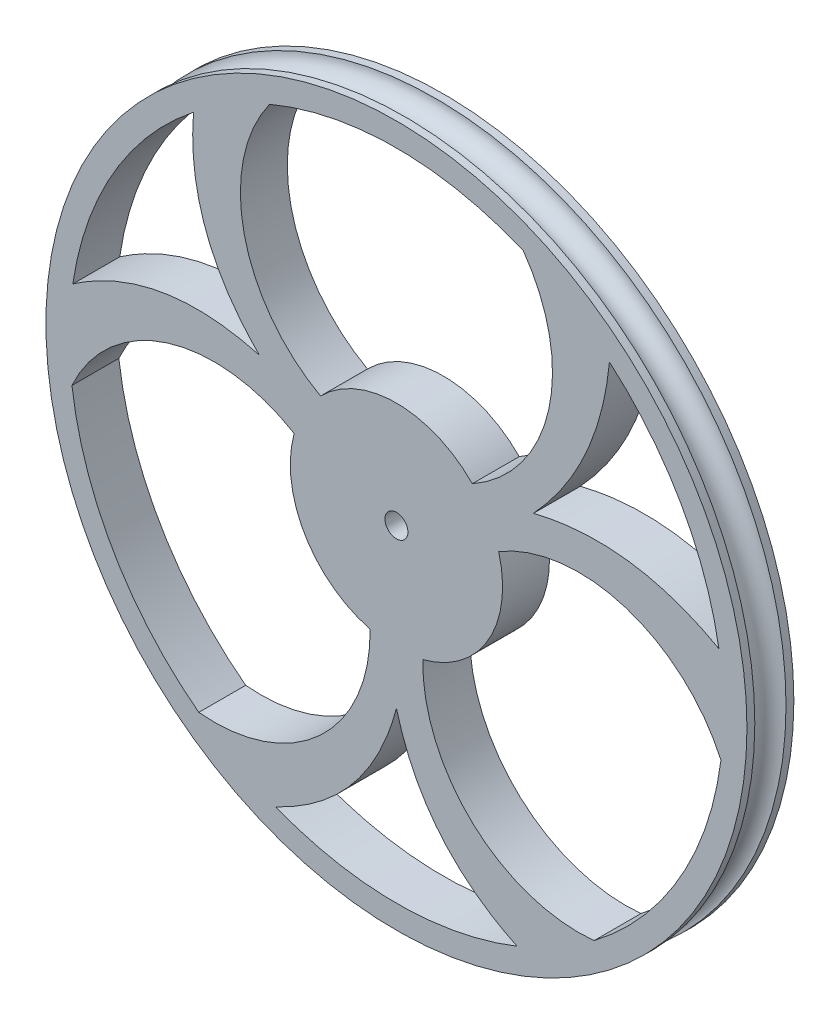
from build123d import *

# Parameters (mm, degrees)
BOSS_EXTRUDE1_REACH                             = 4.654
BOSS_EXTRUDE1_DIRECTION_2_REACH                 = 4.654
CSK_FOR_M2_RAISED_CROSS_HEAD_SCREW1_D           = 2.6
CSK_FOR_M2_RAISED_CROSS_HEAD_SCREW1_CSINK_D     = 4.6
CSK_FOR_M2_RAISED_CROSS_HEAD_SCREW1_CSINK_ANGLE = 92


with BuildPart() as part:
    # Sketch4 → Revolve3 (revolve)
    with BuildSketch(Plane(origin=(0, 0, 0), x_dir=(0, 0, -1), z_dir=(1, 0, 0))):
        with BuildLine():
            Line((-2.6543, -39.6621), (-1.7653, -39.6621))
            ThreePointArc((-1.7653, -39.6621), (0, -37.8968), (1.7653, -39.6621))
            Line((1.7653, -39.6621), (2.6543, -39.6621))
            Line((2.6543, -39.6621), (2.6543, -37.0078))
            Line((2.6543, -37.0078), (-2.6543, -37.0078))
            Line((-2.6543, -37.0078), (-2.6543, -39.6621))
        make_face()
    revolve(axis=Axis((0, 0, 1.7653), (0, 0, -1)))

    # Boss-Extrude1: up to this face of the body (flat: up to its plane)
    boss_extrude1_end = Plane(part.part.faces().sort_by_distance((0, 38.540286405, -2.6543))[0])
    # Sketch5 → Boss-Extrude1 (add, up to the picked face)
    with BuildSketch(Plane.XY, mode=Mode.PRIVATE) as boss_extrude1_sk1:
        with BuildLine():
            ThreePointArc((2.978912783, -11.636990203), (10.402888866, -6.006110687), (11.56738553, 3.238680956))
            ThreePointArc((11.56738553, 3.238680956), (26.749196364, 4.65193852), (37.371776023, -6.286319044))
            ThreePointArc((37.371776023, -6.286319044), (37.895229039, -0.345059896), (37.48005165, 5.604746073))
            add(Edge.make_bspline(
                [(15.506400774, 8.952624661), (27.141070528, 11.852195949), (37.48005165, 5.604746073)],
                knots=[0, 0, 0, 1, 1, 1], degree=2))
            add(Edge.make_bspline(
                [(15.506400774, 8.952624661), (23.43091271, 17.496942665), (24.189816075, 29.172251345)],
                knots=[0, 0, 0, 1, 1, 1], degree=2))
            ThreePointArc((24.189816075, 29.172251345), (18.982008892, 32.800164461), (13.241776023, 35.508066943))
            ThreePointArc((13.241776023, 35.508066943), (17.403295117, 20.839514322), (8.588472748, 8.398309247))
            ThreePointArc((8.588472748, 8.398309247), (0, 12.012221374), (-8.588472748, 8.398309247))
            ThreePointArc((-8.588472748, 8.398309247), (-17.403295117, 20.839514322), (-13.241776023, 35.508066943))
            ThreePointArc((-13.241776023, 35.508066943), (-18.231527824, 33.22316727), (-22.83893963, 30.241532482))
            add(Edge.make_bspline(
                [(-15.506400774, 8.952624661), (-24.330033969, 17.722070983), (-22.83893963, 30.241532482)],
                knots=[0, 0, 0, 1, 1, 1], degree=2))
            add(Edge.make_bspline(
                [(-15.506400774, 8.952624661), (-27.512780663, 12.209392), (-37.609405193, 4.658335674)],
                knots=[0, 0, 0, 1, 1, 1], degree=2))
            ThreePointArc((-37.609405193, 4.658335674), (-37.887870762, -0.822617389), (-37.371776023, -6.286319044))
            ThreePointArc((-37.371776023, -6.286319044), (-26.749196364, 4.65193852), (-11.56738553, 3.238680956))
            ThreePointArc((-11.56738553, 3.238680956), (-10.402888866, -6.006110687), (-2.978912783, -11.636990203))
            ThreePointArc((-2.978912783, -11.636990203), (-9.345901247, -25.491452842), (-24.13, -29.221747898))
            ThreePointArc((-24.13, -29.221747898), (-19.656342938, -32.400549881), (-14.770465564, -34.899868156))
            add(Edge.make_bspline(
                [(0, -17.905249322), (-3.182746695, -29.931462983), (-14.770465564, -34.899868156)],
                knots=[0, 0, 0, 1, 1, 1], degree=2))
            add(Edge.make_bspline(
                [(0, -17.905249322), (3.182746695, -29.931462983), (14.770465564, -34.899868156)],
                knots=[0, 0, 0, 1, 1, 1], degree=2))
            ThreePointArc((14.770465564, -34.899868156), (19.656342938, -32.400549881), (24.13, -29.221747898))
            ThreePointArc((24.13, -29.221747898), (9.345901247, -25.491452842), (2.978912783, -11.636990203))
        make_face()
    boss_extrude1_tool1 = split(extrude(boss_extrude1_sk1.sketch, amount=-BOSS_EXTRUDE1_REACH, mode=Mode.PRIVATE), bisect_by=boss_extrude1_end, keep=Keep.BOTH, mode=Mode.PRIVATE)
    add(boss_extrude1_tool1.solids().sort_by_distance((0.196494, 0.141193, 0))[0])

    # Boss-Extrude1 direction 2: up to this face of the body (flat: up to its plane)
    boss_extrude1_direction_2_end = Plane(part.part.faces().sort_by_distance((0, 38.129613595, 2.6543))[0])
    # Sketch5 → Boss-Extrude1 direction 2 (add, up to the picked face)
    with BuildSketch(Plane.XY, mode=Mode.PRIVATE) as boss_extrude1_direction_2_sk1:
        with BuildLine():
            ThreePointArc((2.978912783, -11.636990203), (10.402888866, -6.006110687), (11.56738553, 3.238680956))
            ThreePointArc((11.56738553, 3.238680956), (26.749196364, 4.65193852), (37.371776023, -6.286319044))
            ThreePointArc((37.371776023, -6.286319044), (37.895229039, -0.345059896), (37.48005165, 5.604746073))
            add(Edge.make_bspline(
                [(15.506400774, 8.952624661), (27.141070528, 11.852195949), (37.48005165, 5.604746073)],
                knots=[0, 0, 0, 1, 1, 1], degree=2))
            add(Edge.make_bspline(
                [(15.506400774, 8.952624661), (23.43091271, 17.496942665), (24.189816075, 29.172251345)],
                knots=[0, 0, 0, 1, 1, 1], degree=2))
            ThreePointArc((24.189816075, 29.172251345), (18.982008892, 32.800164461), (13.241776023, 35.508066943))
            ThreePointArc((13.241776023, 35.508066943), (17.403295117, 20.839514322), (8.588472748, 8.398309247))
            ThreePointArc((8.588472748, 8.398309247), (0, 12.012221374), (-8.588472748, 8.398309247))
            ThreePointArc((-8.588472748, 8.398309247), (-17.403295117, 20.839514322), (-13.241776023, 35.508066943))
            ThreePointArc((-13.241776023, 35.508066943), (-18.231527824, 33.22316727), (-22.83893963, 30.241532482))
            add(Edge.make_bspline(
                [(-15.506400774, 8.952624661), (-24.330033969, 17.722070983), (-22.83893963, 30.241532482)],
                knots=[0, 0, 0, 1, 1, 1], degree=2))
            add(Edge.make_bspline(
                [(-15.506400774, 8.952624661), (-27.512780663, 12.209392), (-37.609405193, 4.658335674)],
                knots=[0, 0, 0, 1, 1, 1], degree=2))
            ThreePointArc((-37.609405193, 4.658335674), (-37.887870762, -0.822617389), (-37.371776023, -6.286319044))
            ThreePointArc((-37.371776023, -6.286319044), (-26.749196364, 4.65193852), (-11.56738553, 3.238680956))
            ThreePointArc((-11.56738553, 3.238680956), (-10.402888866, -6.006110687), (-2.978912783, -11.636990203))
            ThreePointArc((-2.978912783, -11.636990203), (-9.345901247, -25.491452842), (-24.13, -29.221747898))
            ThreePointArc((-24.13, -29.221747898), (-19.656342938, -32.400549881), (-14.770465564, -34.899868156))
            add(Edge.make_bspline(
                [(0, -17.905249322), (-3.182746695, -29.931462983), (-14.770465564, -34.899868156)],
                knots=[0, 0, 0, 1, 1, 1], degree=2))
            add(Edge.make_bspline(
                [(0, -17.905249322), (3.182746695, -29.931462983), (14.770465564, -34.899868156)],
                knots=[0, 0, 0, 1, 1, 1], degree=2))
            ThreePointArc((14.770465564, -34.899868156), (19.656342938, -32.400549881), (24.13, -29.221747898))
            ThreePointArc((24.13, -29.221747898), (9.345901247, -25.491452842), (2.978912783, -11.636990203))
        make_face()
    boss_extrude1_direction_2_tool1 = split(extrude(boss_extrude1_direction_2_sk1.sketch, amount=BOSS_EXTRUDE1_DIRECTION_2_REACH, mode=Mode.PRIVATE), bisect_by=boss_extrude1_direction_2_end, keep=Keep.BOTH, mode=Mode.PRIVATE)
    add(boss_extrude1_direction_2_tool1.solids().sort_by_distance((0.196494, 0.141193, 0))[0])

    # CSK for M2 Raised Cross Head Screw1 (through all)
    with Locations(Plane(origin=(0, 0, -2.6543), x_dir=(-1, 0, 0), z_dir=(0, 0, -1))):
        with Locations((0, 0)):
            CounterSinkHole(CSK_FOR_M2_RAISED_CROSS_HEAD_SCREW1_D / 2, CSK_FOR_M2_RAISED_CROSS_HEAD_SCREW1_CSINK_D / 2, counter_sink_angle=CSK_FOR_M2_RAISED_CROSS_HEAD_SCREW1_CSINK_ANGLE)


solid = part.part
